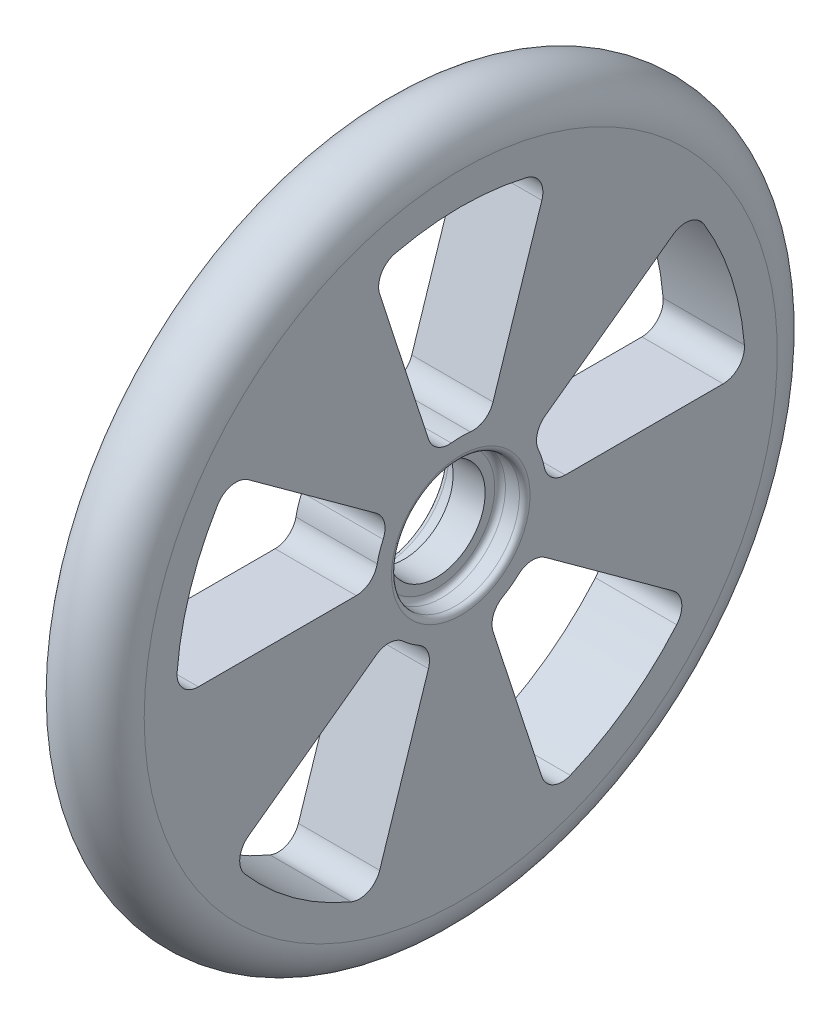
from build123d import *

# Parameters (mm, degrees)
CUT_EXTRUDE1_DEPTH = 7.62
CIRPATTERN1_COUNT  = 5


with BuildPart() as part:
    # Sketch3 → Revolve1 (revolve)
    with BuildSketch(Plane.XY):
        with BuildLine():
            Line((-1.5, 4.6), (1.5, 4.6))
            Line((1.5, 4.6), (1.5, 5.5))
            ThreePointArc((1.5, 5.5), (1.646446609, 5.853553391), (2, 6))
            Line((2, 6), (3.31, 6))
            ThreePointArc((3.31, 6), (3.663553391, 6.146446609), (3.81, 6.5))
            Line((3.81, 6.5), (3.81, 29.69))
            ThreePointArc((3.81, 29.69), (0, 33.5), (-3.81, 29.69))
            Line((-3.81, 29.69), (-3.81, 6.5))
            ThreePointArc((-3.81, 6.5), (-3.663553391, 6.146446609), (-3.31, 6))
            Line((-3.31, 6), (-2, 6))
            ThreePointArc((-2, 6), (-1.646446609, 5.853553391), (-1.5, 5.5))
            Line((-1.5, 5.5), (-1.5, 4.6))
        make_face()
    revolve(axis=Axis((0, 0, 0), (1, 0, 0)))

    # Sketch6 → Cut-Extrude1 (cut)
    with BuildSketch(Plane(origin=(3.81, 0, 0), x_dir=(0, 0, -1), z_dir=(1, 0, 0))):
        with BuildLine():
            Line((7.926715318, 5.759095786), (19.908987752, 14.464726291))
            ThreePointArc((19.908987752, 14.464726291), (21.477243007, 14.807763104), (22.792501412, 13.887331614))
            ThreePointArc((22.792501412, 13.887331614), (25.38369842, 8.24766358), (26.602289704, 2.16200891))
            ThreePointArc((26.602289704, 2.16200891), (26.079239357, 0.6442747), (24.608862225, 0))
            Line((24.608862225, 0), (9.797958971, 0))
            ThreePointArc((9.797958971, 0), (8.533047907, 0.450806662), (7.838367177, 1.6))
            ThreePointArc((7.838367177, 1.6), (7.60845213, 2.472135955), (7.281828658, 3.312849438))
            ThreePointArc((7.281828658, 3.312849438), (7.168358278, 4.650889467), (7.926715318, 5.759095786))
        make_face()
    cut_extrude1 = extrude(amount=-CUT_EXTRUDE1_DEPTH, mode=Mode.SUBTRACT)

    # CirPattern1: Cut-Extrude1 ×5 about axis
    cirpattern1_axis = Axis((0, 0, 0), (1, 0, 0))
    for i in range(1, CIRPATTERN1_COUNT):
        add(cut_extrude1.rotate(cirpattern1_axis, i * 360 / CIRPATTERN1_COUNT), mode=Mode.SUBTRACT)


solid = part.part
